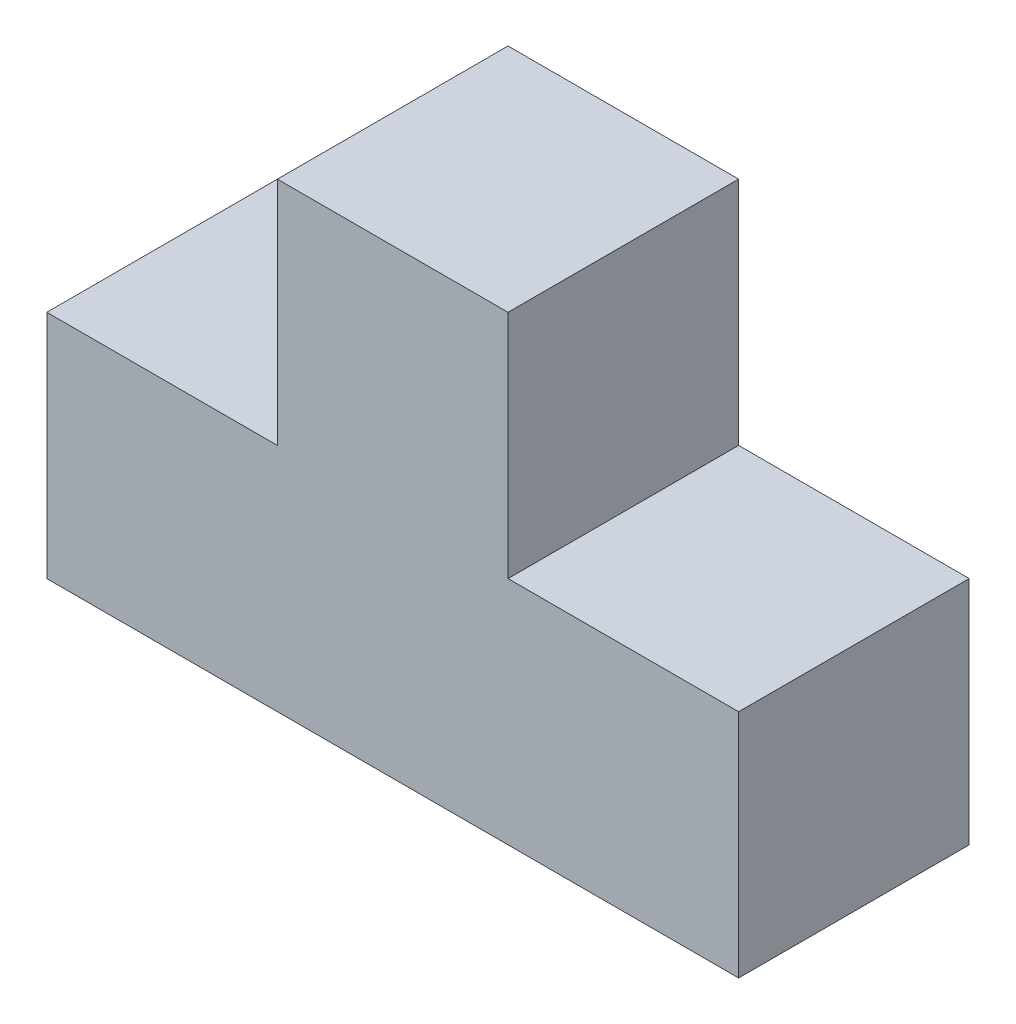
from build123d import *

# Parameters (mm, degrees)
BOSS_EXTRU_1_DEPTH = 30


with BuildPart() as part:
    # Esquisse2 → Boss.-Extru.1 (new body)
    with BuildSketch(Plane.XY):
        Polygon((0, 0), (90, 0), (90, 30), (60, 30), (60, 60), (30, 60), (30, 30), (0, 30), align=None)
    extrude(amount=BOSS_EXTRU_1_DEPTH)


solid = part.part
